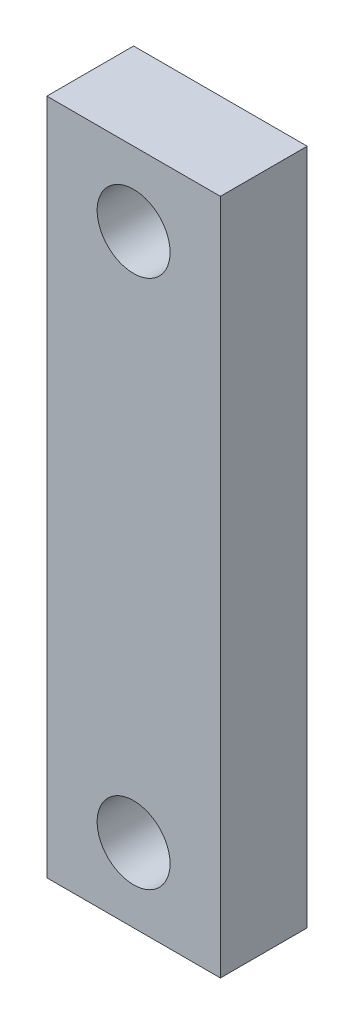
from build123d import *

# Parameters (mm, degrees)
SKETCH1_W            = 20
SKETCH1_H            = 78
BOSS_EXTRUDE1_DEPTH  = 10
M8_CLEARANCE_HOLE1_D = 8.4


with BuildPart() as part:
    # Sketch1 → Boss-Extrude1 (new body)
    with BuildSketch(Plane.XY):
        Rectangle(SKETCH1_W, SKETCH1_H)
    extrude(amount=BOSS_EXTRUDE1_DEPTH)

    # M8 Clearance Hole1 (through all)
    with Locations(Plane.XY.offset(10)):
        with Locations((0, 30.5), (0, -30.5)):
            Hole(M8_CLEARANCE_HOLE1_D / 2)


solid = part.part
